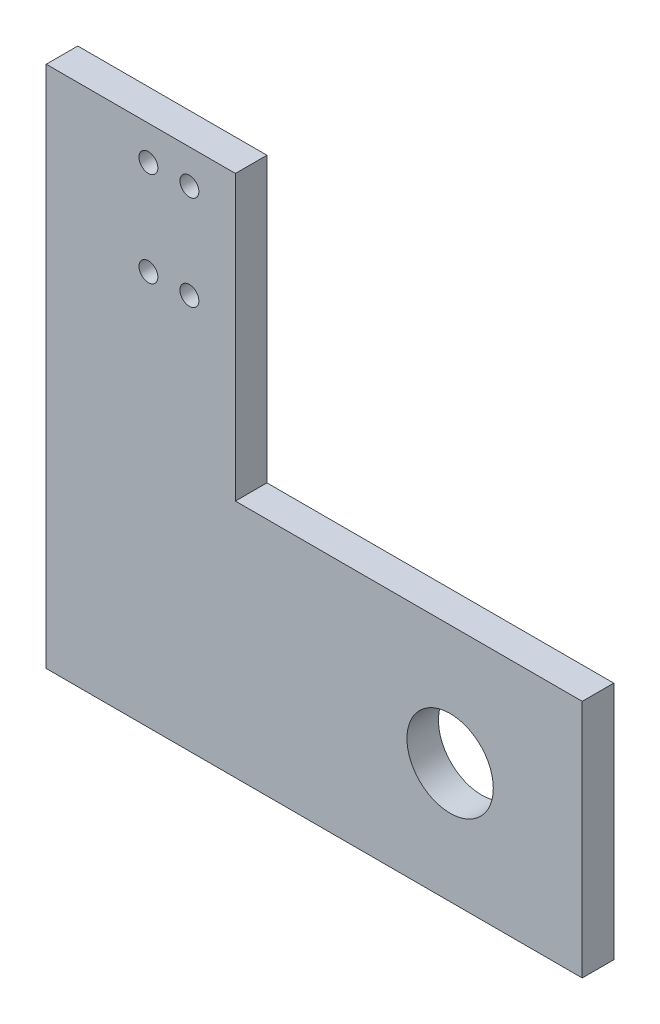
from build123d import *

# Parameters (mm, degrees)
SKETCH_7_R      = 1.5
SKETCH_7_R_2    = 6.85
EXTRUDE_6_DEPTH = 5


with BuildPart() as part:
    # 草图7 → 凸台-拉伸6 (new body)
    with BuildSketch(Plane.XY):
        Polygon((2345.47122728, 4698.976172331), (2345.47122728, 4743.976172331), (2315.47122728, 4743.976172331), (2315.47122728, 4660.976172331), (2400.47122728, 4660.976172331), (2400.47122728, 4698.976172331), align=None)
        with Locations((2338.172409077, 4738.576172331)):
            Circle(SKETCH_7_R, mode=Mode.SUBTRACT)
        with Locations((2338.172409077, 4723.576172331)):
            Circle(SKETCH_7_R, mode=Mode.SUBTRACT)
        with Locations((2331.672409077, 4738.576172331)):
            Circle(SKETCH_7_R, mode=Mode.SUBTRACT)
        with Locations((2331.672409077, 4723.576172331)):
            Circle(SKETCH_7_R, mode=Mode.SUBTRACT)
        with Locations((2379.518247339, 4679.976172331)):
            Circle(SKETCH_7_R_2, mode=Mode.SUBTRACT)
    extrude(amount=EXTRUDE_6_DEPTH)


solid = part.part
